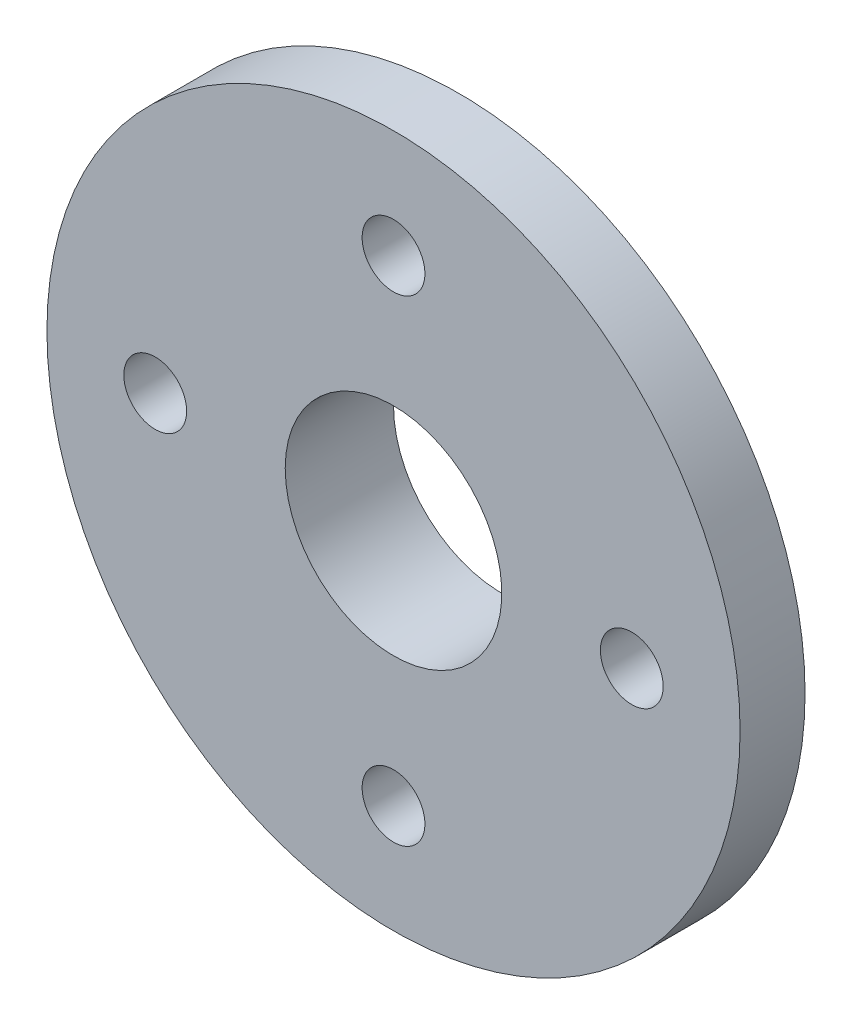
from build123d import *

# Parameters (mm, degrees)
SKETCH_1_R      = 8
SKETCH_1_R_2    = 5
EXTRUDE_1_DEPTH = 5
SKETCH_4_R      = 16
SKETCH_4_R_2    = 8
EXTRUDE_2_DEPTH = 3
SKETCH_5_R      = 16
SKETCH_5_R_2    = 12.5
EXTRUDE_3_DEPTH = 3
ST2_9_1_D       = 2.9


with BuildPart() as part:
    # 草图1 → 凸台-拉伸1 (new body)
    with BuildSketch(Plane(origin=(0, 0, 606.712583837), x_dir=(-1, 0, 0), z_dir=(0, 0, -1))):
        with Locations((-4.295303519, -1.225452996)):
            Circle(SKETCH_1_R)
        with Locations((-4.295303519, -1.225452996)):
            Circle(SKETCH_1_R_2, mode=Mode.SUBTRACT)
    extrude(amount=EXTRUDE_1_DEPTH)

    # 草图4 → 凸台-拉伸2 (add)
    with BuildSketch(Plane(origin=(0, 0, 606.712583837), x_dir=(-1, 0, 0), z_dir=(0, 0, -1))):
        with Locations((-4.295303519, -1.225452996)):
            Circle(SKETCH_4_R)
        with Locations((-4.295303519, -1.225452996)):
            Circle(SKETCH_4_R_2, mode=Mode.SUBTRACT)
    extrude(amount=EXTRUDE_2_DEPTH)

    # 草图5 → 凸台-拉伸3 (add)
    with BuildSketch(Plane(origin=(0, 0, 603.712583837), x_dir=(-1, 0, 0), z_dir=(0, 0, -1))):
        with Locations((-4.295303519, -1.225452996)):
            Circle(SKETCH_5_R)
        with Locations((-4.295303519, -1.225452996)):
            Circle(SKETCH_5_R_2, mode=Mode.SUBTRACT)
    extrude(amount=-EXTRUDE_3_DEPTH)

    # ST2.9 间隙孔1 (through all)
    with Locations(Plane(origin=(0, 0, 603.712583837), x_dir=(-1, 0, 0), z_dir=(0, 0, -1))):
        with Locations((-4.295303519, 9.774547004), (6.704696481, -1.225452996), (-4.295303519, -12.225452996), (-15.295303519, -1.225452996)):
            Hole(ST2_9_1_D / 2)


solid = part.part
